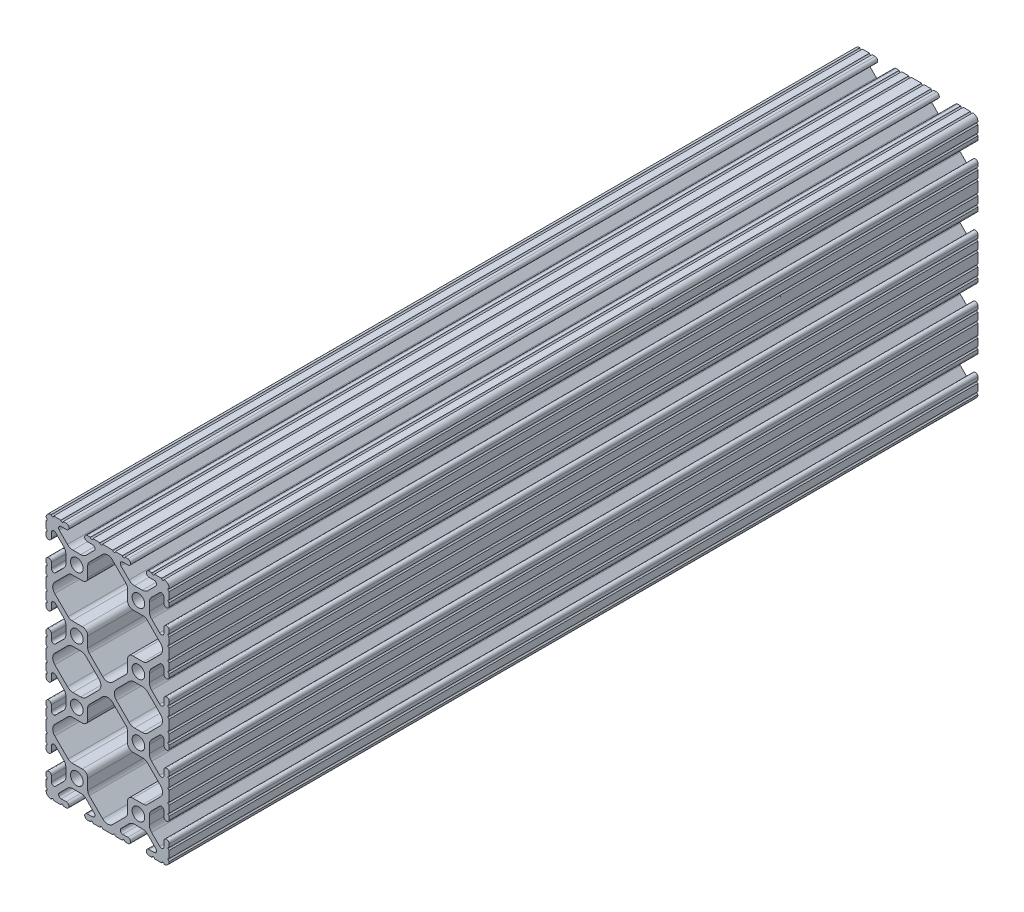
from build123d import *

# Parameters (mm, degrees)
SKETCH1_R      = 2.6035
EXTRUDE1_DEPTH = 333.375


with BuildPart() as part:
    # Sketch1 → Extrude1 (new body)
    with BuildSketch(Plane.XY):
        with BuildLine():
            Line((-12.699984366, 40.2336), (-12.699984366, 35.9664))
            ThreePointArc((-12.699984366, 35.9664), (-12.192, 35.458392183), (-12.7, 34.9504))
            Line((-12.7, 34.9504), (-12.7, 32.004))
            ThreePointArc((-12.7, 32.004), (-12.192, 31.496), (-12.7, 30.988))
            Line((-12.7, 30.988), (-12.7, 29.7434))
            ThreePointArc((-12.7, 29.7434), (-11.5951, 28.6385), (-10.4902, 29.7434))
            Line((-10.4902, 29.7434), (-10.4902, 31.874256981))
            ThreePointArc((-10.4902, 31.874256981), (-9.863010627, 32.812916821), (-8.755786031, 32.592683991))
            Line((-8.755786031, 32.592683991), (-5.425756348, 29.262714761))
            ThreePointArc((-5.425756348, 29.262714761), (-4.737487999, 28.232663563), (-4.4958, 27.017630353))
            Line((-4.4958, 27.017630353), (-4.4958, 23.782369647))
            ThreePointArc((-4.4958, 23.782369647), (-4.737487999, 22.567336437), (-5.425756348, 21.537285239))
            Line((-5.425756348, 21.537285239), (-8.755786031, 18.207316009))
            ThreePointArc((-8.755786031, 18.207316009), (-9.863010627, 17.987083179), (-10.4902, 18.925743019))
            Line((-10.4902, 18.925743019), (-10.4902, 21.0566))
            ThreePointArc((-10.4902, 21.0566), (-11.5951, 22.1615), (-12.7, 21.0566))
            Line((-12.7, 21.0566), (-12.7, 19.812))
            ThreePointArc((-12.7, 19.812), (-12.192, 19.304), (-12.7, 18.796))
            Line((-12.7, 18.796), (-12.7, 15.8496))
            ThreePointArc((-12.7, 15.8496), (-12.192, 15.341607817), (-12.699984366, 14.8336))
            Line((-12.699984366, 14.8336), (-12.699984366, 10.5664))
            ThreePointArc((-12.699984366, 10.5664), (-12.192, 10.0584), (-12.699984366, 9.5504))
            Line((-12.699984366, 9.5504), (-12.699984366, 6.604))
            ThreePointArc((-12.699984366, 6.604), (-12.192, 6.095992183), (-12.7, 5.588))
            Line((-12.7, 5.588), (-12.7, 4.3434))
            ThreePointArc((-12.7, 4.3434), (-11.5951, 3.2385), (-10.4902, 4.3434))
            Line((-10.4902, 4.3434), (-10.4902, 6.474256981))
            ThreePointArc((-10.4902, 6.474256981), (-9.863010627, 7.412916821), (-8.755786031, 7.192683991))
            Line((-8.755786031, 7.192683991), (-5.425756348, 3.862714761))
            ThreePointArc((-5.425756348, 3.862714761), (-4.737487999, 2.832663563), (-4.4958, 1.617630353))
            Line((-4.4958, 1.617630353), (-4.4958, -1.617630353))
            ThreePointArc((-4.4958, -1.617630353), (-4.737487999, -2.832663563), (-5.425756348, -3.862714761))
            Line((-5.425756348, -3.862714761), (-8.755786031, -7.192683991))
            ThreePointArc((-8.755786031, -7.192683991), (-9.863010627, -7.412916821), (-10.4902, -6.474256981))
            Line((-10.4902, -6.474256981), (-10.4902, -4.3434))
            ThreePointArc((-10.4902, -4.3434), (-11.5951, -3.2385), (-12.7, -4.3434))
            Line((-12.7, -4.3434), (-12.7, -5.588))
            ThreePointArc((-12.7, -5.588), (-12.192, -6.096), (-12.7, -6.604))
            Line((-12.7, -6.604), (-12.7, -9.5504))
            ThreePointArc((-12.7, -9.5504), (-12.192000007, -10.058315768), (-12.699831537, -10.566399972))
            ThreePointArc((-12.699831537, -10.566399972), (-12.082506882, -12.082506882), (-10.566399972, -12.699831537))
            ThreePointArc((-10.566399972, -12.699831537), (-10.058315768, -12.192000007), (-9.5504, -12.7))
            Line((-9.5504, -12.7), (-6.604, -12.7))
            ThreePointArc((-6.604, -12.7), (-6.096, -12.192), (-5.588, -12.7))
            Line((-5.588, -12.7), (-4.3434, -12.7))
            ThreePointArc((-4.3434, -12.7), (-3.2385, -11.5951), (-4.3434, -10.4902))
            Line((-4.3434, -10.4902), (-6.474256981, -10.4902))
            ThreePointArc((-6.474256981, -10.4902), (-7.412916821, -9.863010627), (-7.192683991, -8.755786031))
            Line((-7.192683991, -8.755786031), (-3.862714761, -5.425756348))
            ThreePointArc((-3.862714761, -5.425756348), (-2.832663563, -4.737487999), (-1.617630353, -4.4958))
            Line((-1.617630353, -4.4958), (1.617630353, -4.4958))
            ThreePointArc((1.617630353, -4.4958), (2.832663563, -4.737487999), (3.862714761, -5.425756348))
            Line((3.862714761, -5.425756348), (7.192683991, -8.755786031))
            ThreePointArc((7.192683991, -8.755786031), (7.412916821, -9.863010627), (6.474256981, -10.4902))
            Line((6.474256981, -10.4902), (4.3434, -10.4902))
            ThreePointArc((4.3434, -10.4902), (3.2385, -11.5951), (4.3434, -12.7))
            Line((4.3434, -12.7), (5.588, -12.7))
            ThreePointArc((5.588, -12.7), (6.096, -12.192), (6.604, -12.7))
            Line((6.604, -12.7), (9.5504, -12.7))
            ThreePointArc((9.5504, -12.7), (10.0584, -12.192), (10.5664, -12.7))
            Line((10.5664, -12.7), (14.8336, -12.7))
            ThreePointArc((14.8336, -12.7), (15.3416, -12.192), (15.8496, -12.7))
            Line((15.8496, -12.7), (18.796, -12.7))
            ThreePointArc((18.796, -12.7), (19.304, -12.192), (19.812, -12.7))
            Line((19.812, -12.7), (21.0566, -12.7))
            ThreePointArc((21.0566, -12.7), (22.1615, -11.5951), (21.0566, -10.4902))
            Line((21.0566, -10.4902), (18.925743019, -10.4902))
            ThreePointArc((18.925743019, -10.4902), (17.987083179, -9.863010627), (18.207316009, -8.755786031))
            Line((18.207316009, -8.755786031), (21.537285239, -5.425756348))
            ThreePointArc((21.537285239, -5.425756348), (22.567336437, -4.737487999), (23.782369647, -4.4958))
            Line((23.782369647, -4.4958), (27.017630353, -4.4958))
            ThreePointArc((27.017630353, -4.4958), (28.232663563, -4.737487999), (29.262714761, -5.425756348))
            Line((29.262714761, -5.425756348), (32.592683991, -8.755786031))
            ThreePointArc((32.592683991, -8.755786031), (32.812916821, -9.863010627), (31.874256981, -10.4902))
            Line((31.874256981, -10.4902), (29.7434, -10.4902))
            ThreePointArc((29.7434, -10.4902), (28.6385, -11.5951), (29.7434, -12.7))
            Line((29.7434, -12.7), (30.988, -12.7))
            ThreePointArc((30.988, -12.7), (31.496, -12.192), (32.004, -12.7))
            Line((32.004, -12.7), (34.9504, -12.7))
            ThreePointArc((34.9504, -12.7), (35.458315768, -12.192000007), (35.966399972, -12.699831537))
            ThreePointArc((35.966399972, -12.699831537), (37.482506882, -12.082506882), (38.099831537, -10.566399972))
            ThreePointArc((38.099831537, -10.566399972), (37.592000007, -10.058315768), (38.1, -9.5504))
            Line((38.1, -9.5504), (38.1, -6.604))
            ThreePointArc((38.1, -6.604), (37.592, -6.096), (38.1, -5.588))
            Line((38.1, -5.588), (38.1, -4.3434))
            ThreePointArc((38.1, -4.3434), (36.9951, -3.2385), (35.8902, -4.3434))
            Line((35.8902, -4.3434), (35.8902, -6.474256981))
            ThreePointArc((35.8902, -6.474256981), (35.263010627, -7.412916821), (34.155786031, -7.192683991))
            Line((34.155786031, -7.192683991), (30.825756348, -3.862714761))
            ThreePointArc((30.825756348, -3.862714761), (30.137487999, -2.832663563), (29.8958, -1.617630353))
            Line((29.8958, -1.617630353), (29.8958, 1.617630353))
            ThreePointArc((29.8958, 1.617630353), (30.137487999, 2.832663563), (30.825756348, 3.862714761))
            Line((30.825756348, 3.862714761), (34.155786031, 7.192683991))
            ThreePointArc((34.155786031, 7.192683991), (35.263010627, 7.412916821), (35.8902, 6.474256981))
            Line((35.8902, 6.474256981), (35.8902, 4.3434))
            ThreePointArc((35.8902, 4.3434), (36.9951, 3.2385), (38.1, 4.3434))
            Line((38.1, 4.3434), (38.1, 5.588))
            ThreePointArc((38.1, 5.588), (37.592, 6.096), (38.1, 6.604))
            Line((38.1, 6.604), (38.1, 9.5504))
            ThreePointArc((38.1, 9.5504), (37.592, 10.058392183), (38.099984366, 10.5664))
            Line((38.099984366, 10.5664), (38.099984366, 14.8336))
            ThreePointArc((38.099984366, 14.8336), (37.592, 15.3416), (38.099984366, 15.8496))
            Line((38.099984366, 15.8496), (38.099984366, 18.796))
            ThreePointArc((38.099984366, 18.796), (37.592, 19.304007817), (38.1, 19.812))
            Line((38.1, 19.812), (38.1, 21.0566))
            ThreePointArc((38.1, 21.0566), (36.9951, 22.1615), (35.8902, 21.0566))
            Line((35.8902, 21.0566), (35.8902, 18.925743019))
            ThreePointArc((35.8902, 18.925743019), (35.263010627, 17.987083179), (34.155786031, 18.207316009))
            Line((34.155786031, 18.207316009), (30.825756348, 21.537285239))
            ThreePointArc((30.825756348, 21.537285239), (30.137487999, 22.567336437), (29.8958, 23.782369647))
            Line((29.8958, 23.782369647), (29.8958, 27.017630353))
            ThreePointArc((29.8958, 27.017630353), (30.137487999, 28.232663563), (30.825756348, 29.262714761))
            Line((30.825756348, 29.262714761), (34.155786031, 32.592683991))
            ThreePointArc((34.155786031, 32.592683991), (35.263010627, 32.812916821), (35.8902, 31.874256981))
            Line((35.8902, 31.874256981), (35.8902, 29.7434))
            ThreePointArc((35.8902, 29.7434), (36.9951, 28.6385), (38.1, 29.7434))
            Line((38.1, 29.7434), (38.1, 30.988))
            ThreePointArc((38.1, 30.988), (37.592, 31.495992183), (38.099984366, 32.004))
            Line((38.099984366, 32.004), (38.099984366, 34.9504))
            ThreePointArc((38.099984366, 34.9504), (37.592, 35.4584), (38.099984366, 35.9664))
            Line((38.099984366, 35.9664), (38.099984366, 40.2336))
            ThreePointArc((38.099984366, 40.2336), (37.592, 40.7416), (38.099984366, 41.2496))
            Line((38.099984366, 41.2496), (38.099984366, 44.196))
            ThreePointArc((38.099984366, 44.196), (37.592, 44.704007817), (38.1, 45.212))
            Line((38.1, 45.212), (38.1, 46.4566))
            ThreePointArc((38.1, 46.4566), (36.9951, 47.5615), (35.8902, 46.4566))
            Line((35.8902, 46.4566), (35.8902, 44.325743019))
            ThreePointArc((35.8902, 44.325743019), (35.263010627, 43.387083179), (34.155786031, 43.607316009))
            Line((34.155786031, 43.607316009), (30.825756348, 46.937285239))
            ThreePointArc((30.825756348, 46.937285239), (30.137487999, 47.967336437), (29.8958, 49.182369647))
            Line((29.8958, 49.182369647), (29.8958, 52.417630353))
            ThreePointArc((29.8958, 52.417630353), (30.137487999, 53.632663563), (30.825756348, 54.662714761))
            Line((30.825756348, 54.662714761), (34.155786031, 57.992683991))
            ThreePointArc((34.155786031, 57.992683991), (35.263010627, 58.212916821), (35.8902, 57.274256981))
            Line((35.8902, 57.274256981), (35.8902, 55.1434))
            ThreePointArc((35.8902, 55.1434), (36.9951, 54.0385), (38.1, 55.1434))
            Line((38.1, 55.1434), (38.1, 56.388))
            ThreePointArc((38.1, 56.388), (37.592, 56.896), (38.1, 57.404))
            Line((38.1, 57.404), (38.1, 60.3504))
            ThreePointArc((38.1, 60.3504), (37.592, 60.858392183), (38.099984366, 61.3664))
            Line((38.099984366, 61.3664), (38.099984366, 65.6336))
            ThreePointArc((38.099984366, 65.6336), (37.592, 66.141607817), (38.1, 66.6496))
            Line((38.1, 66.6496), (38.1, 69.596))
            ThreePointArc((38.1, 69.596), (37.592, 70.104), (38.1, 70.612))
            Line((38.1, 70.612), (38.1, 71.8566))
            ThreePointArc((38.1, 71.8566), (36.9951, 72.9615), (35.8902, 71.8566))
            Line((35.8902, 71.8566), (35.8902, 69.725743019))
            ThreePointArc((35.8902, 69.725743019), (35.263010627, 68.787083179), (34.155786031, 69.007316009))
            Line((34.155786031, 69.007316009), (30.825756348, 72.337285239))
            ThreePointArc((30.825756348, 72.337285239), (30.137487999, 73.367336437), (29.8958, 74.582369647))
            Line((29.8958, 74.582369647), (29.8958, 77.817630353))
            ThreePointArc((29.8958, 77.817630353), (30.137487999, 79.032663563), (30.825756348, 80.062714761))
            Line((30.825756348, 80.062714761), (34.155786031, 83.392683991))
            ThreePointArc((34.155786031, 83.392683991), (35.263010627, 83.612916821), (35.8902, 82.674256981))
            Line((35.8902, 82.674256981), (35.8902, 80.5434))
            ThreePointArc((35.8902, 80.5434), (36.9951, 79.4385), (38.1, 80.5434))
            Line((38.1, 80.5434), (38.1, 81.788))
            ThreePointArc((38.1, 81.788), (37.592, 82.296), (38.1, 82.804))
            Line((38.1, 82.804), (38.1, 85.7504))
            ThreePointArc((38.1, 85.7504), (37.592000007, 86.258315768), (38.099831537, 86.766399972))
            ThreePointArc((38.099831537, 86.766399972), (37.482506882, 88.282506882), (35.966399972, 88.899831537))
            ThreePointArc((35.966399972, 88.899831537), (35.458315768, 88.392000007), (34.9504, 88.9))
            Line((34.9504, 88.9), (32.004, 88.9))
            ThreePointArc((32.004, 88.9), (31.496, 88.392), (30.988, 88.9))
            Line((30.988, 88.9), (29.7434, 88.9))
            ThreePointArc((29.7434, 88.9), (28.6385, 87.7951), (29.7434, 86.6902))
            Line((29.7434, 86.6902), (31.874256981, 86.6902))
            ThreePointArc((31.874256981, 86.6902), (32.812916821, 86.063010627), (32.592683991, 84.955786031))
            Line((32.592683991, 84.955786031), (29.262714761, 81.625756348))
            ThreePointArc((29.262714761, 81.625756348), (28.232663563, 80.937487999), (27.017630353, 80.6958))
            Line((27.017630353, 80.6958), (23.782369647, 80.6958))
            ThreePointArc((23.782369647, 80.6958), (22.567336437, 80.937487999), (21.537285239, 81.625756348))
            Line((21.537285239, 81.625756348), (18.207316009, 84.955786031))
            ThreePointArc((18.207316009, 84.955786031), (17.987083179, 86.063010627), (18.925743019, 86.6902))
            Line((18.925743019, 86.6902), (21.0566, 86.6902))
            ThreePointArc((21.0566, 86.6902), (22.1615, 87.7951), (21.0566, 88.9))
            Line((21.0566, 88.9), (19.812, 88.9))
            ThreePointArc((19.812, 88.9), (19.304, 88.392), (18.796, 88.9))
            Line((18.796, 88.9), (15.8496, 88.9))
            ThreePointArc((15.8496, 88.9), (15.3416, 88.392), (14.8336, 88.9))
            Line((14.8336, 88.9), (10.5664, 88.9))
            ThreePointArc((10.5664, 88.9), (10.0584, 88.392), (9.5504, 88.9))
            Line((9.5504, 88.9), (6.604, 88.9))
            ThreePointArc((6.604, 88.9), (6.096, 88.392), (5.588, 88.9))
            Line((5.588, 88.9), (4.3434, 88.9))
            ThreePointArc((4.3434, 88.9), (3.2385, 87.7951), (4.3434, 86.6902))
            Line((4.3434, 86.6902), (6.474256981, 86.6902))
            ThreePointArc((6.474256981, 86.6902), (7.412916821, 86.063010627), (7.192683991, 84.955786031))
            Line((7.192683991, 84.955786031), (3.862714761, 81.625756348))
            ThreePointArc((3.862714761, 81.625756348), (2.832663563, 80.937487999), (1.617630353, 80.6958))
            Line((1.617630353, 80.6958), (-1.617630353, 80.6958))
            ThreePointArc((-1.617630353, 80.6958), (-2.832663563, 80.937487999), (-3.862714761, 81.625756348))
            Line((-3.862714761, 81.625756348), (-7.192683991, 84.955786031))
            ThreePointArc((-7.192683991, 84.955786031), (-7.412916821, 86.063010627), (-6.474256981, 86.6902))
            Line((-6.474256981, 86.6902), (-4.3434, 86.6902))
            ThreePointArc((-4.3434, 86.6902), (-3.2385, 87.7951), (-4.3434, 88.9))
            Line((-4.3434, 88.9), (-5.588, 88.9))
            ThreePointArc((-5.588, 88.9), (-6.096, 88.392), (-6.604, 88.9))
            Line((-6.604, 88.9), (-9.5504, 88.9))
            ThreePointArc((-9.5504, 88.9), (-10.058315768, 88.392000007), (-10.566399972, 88.899831537))
            ThreePointArc((-10.566399972, 88.899831537), (-12.082506882, 88.282506882), (-12.699831537, 86.766399972))
            ThreePointArc((-12.699831537, 86.766399972), (-12.192000007, 86.258315768), (-12.7, 85.7504))
            Line((-12.7, 85.7504), (-12.7, 82.804))
            ThreePointArc((-12.7, 82.804), (-12.192, 82.296), (-12.7, 81.788))
            Line((-12.7, 81.788), (-12.7, 80.5434))
            ThreePointArc((-12.7, 80.5434), (-11.5951, 79.4385), (-10.4902, 80.5434))
            Line((-10.4902, 80.5434), (-10.4902, 82.674256981))
            ThreePointArc((-10.4902, 82.674256981), (-9.863010627, 83.612916821), (-8.755786031, 83.392683991))
            Line((-8.755786031, 83.392683991), (-5.425756348, 80.062714761))
            ThreePointArc((-5.425756348, 80.062714761), (-4.737487999, 79.032663563), (-4.4958, 77.817630353))
            Line((-4.4958, 77.817630353), (-4.4958, 74.582369647))
            ThreePointArc((-4.4958, 74.582369647), (-4.737487999, 73.367336437), (-5.425756348, 72.337285239))
            Line((-5.425756348, 72.337285239), (-8.755786031, 69.007316009))
            ThreePointArc((-8.755786031, 69.007316009), (-9.863010627, 68.787083179), (-10.4902, 69.725743019))
            Line((-10.4902, 69.725743019), (-10.4902, 71.8566))
            ThreePointArc((-10.4902, 71.8566), (-11.5951, 72.9615), (-12.7, 71.8566))
            Line((-12.7, 71.8566), (-12.7, 70.612))
            ThreePointArc((-12.7, 70.612), (-12.192, 70.104), (-12.7, 69.596))
            Line((-12.7, 69.596), (-12.7, 66.6496))
            ThreePointArc((-12.7, 66.6496), (-12.192, 66.141607817), (-12.699984366, 65.6336))
            Line((-12.699984366, 65.6336), (-12.699984366, 61.3664))
            ThreePointArc((-12.699984366, 61.3664), (-12.192, 60.858392183), (-12.7, 60.3504))
            Line((-12.7, 60.3504), (-12.7, 57.404))
            ThreePointArc((-12.7, 57.404), (-12.192, 56.896), (-12.7, 56.388))
            Line((-12.7, 56.388), (-12.7, 55.1434))
            ThreePointArc((-12.7, 55.1434), (-11.5951, 54.0385), (-10.4902, 55.1434))
            Line((-10.4902, 55.1434), (-10.4902, 57.274256981))
            ThreePointArc((-10.4902, 57.274256981), (-9.863010627, 58.212916821), (-8.755786031, 57.992683991))
            Line((-8.755786031, 57.992683991), (-5.425756348, 54.662714761))
            ThreePointArc((-5.425756348, 54.662714761), (-4.737487999, 53.632663563), (-4.4958, 52.417630353))
            Line((-4.4958, 52.417630353), (-4.4958, 49.182369647))
            ThreePointArc((-4.4958, 49.182369647), (-4.737487999, 47.967336437), (-5.425756348, 46.937285239))
            Line((-5.425756348, 46.937285239), (-8.755786031, 43.607316009))
            ThreePointArc((-8.755786031, 43.607316009), (-9.863010627, 43.387083179), (-10.4902, 44.325743019))
            Line((-10.4902, 44.325743019), (-10.4902, 46.4566))
            ThreePointArc((-10.4902, 46.4566), (-11.5951, 47.5615), (-12.7, 46.4566))
            Line((-12.7, 46.4566), (-12.7, 45.212))
            ThreePointArc((-12.7, 45.212), (-12.192, 44.704), (-12.7, 44.196))
            Line((-12.7, 44.196), (-12.7, 41.2496))
            ThreePointArc((-12.7, 41.2496), (-12.192, 40.741607817), (-12.699984366, 40.2336))
        make_face()
        with Locations((25.4, 76.2)):
            Circle(SKETCH1_R, mode=Mode.SUBTRACT)
        with Locations((0, 76.2)):
            Circle(SKETCH1_R, mode=Mode.SUBTRACT)
        with Locations((25.4, 50.8)):
            Circle(SKETCH1_R, mode=Mode.SUBTRACT)
        with Locations((0, 50.8)):
            Circle(SKETCH1_R, mode=Mode.SUBTRACT)
        with Locations((25.4, 0)):
            Circle(SKETCH1_R, mode=Mode.SUBTRACT)
        Circle(SKETCH1_R, mode=Mode.SUBTRACT)
        with Locations((25.4, 25.4)):
            Circle(SKETCH1_R, mode=Mode.SUBTRACT)
        with Locations((0, 25.4)):
            Circle(SKETCH1_R, mode=Mode.SUBTRACT)
        with BuildLine():
            Line((2.286, 55.2958), (-2.018378203, 55.2958))
            ThreePointArc((-2.018378203, 55.2958), (-2.864022786, 55.464007171), (-3.580928584, 55.943021252))
            Line((-3.580928584, 55.943021252), (-9.072529371, 61.434522344))
            ThreePointArc((-9.072529371, 61.434522344), (-9.928089211, 63.5), (-9.072529371, 65.565477656))
            Line((-9.072529371, 65.565477656), (-3.580928584, 71.056978748))
            ThreePointArc((-3.580928584, 71.056978748), (-2.864022786, 71.535992829), (-2.018378203, 71.7042))
            Line((-2.018378203, 71.7042), (2.286, 71.7042))
            ThreePointArc((2.286, 71.7042), (3.848564565, 72.351435435), (4.4958, 73.914))
            Line((4.4958, 73.914), (4.4958, 78.218378203))
            ThreePointArc((4.4958, 78.218378203), (4.664007171, 79.064022786), (5.143021252, 79.780928584))
            Line((5.143021252, 79.780928584), (10.634522344, 85.272529371))
            ThreePointArc((10.634522344, 85.272529371), (12.7, 86.128089211), (14.765477656, 85.272529371))
            Line((14.765477656, 85.272529371), (20.256978748, 79.780928584))
            ThreePointArc((20.256978748, 79.780928584), (20.735992829, 79.064022786), (20.9042, 78.218378203))
            Line((20.9042, 78.218378203), (20.9042, 73.914))
            ThreePointArc((20.9042, 73.914), (21.551435435, 72.351435435), (23.114, 71.7042))
            Line((23.114, 71.7042), (27.418378203, 71.7042))
            ThreePointArc((27.418378203, 71.7042), (28.264022786, 71.535992829), (28.980928584, 71.056978748))
            Line((28.980928584, 71.056978748), (34.472529371, 65.565477656))
            ThreePointArc((34.472529371, 65.565477656), (35.328089211, 63.5), (34.472529371, 61.434522344))
            Line((34.472529371, 61.434522344), (28.980928584, 55.943021252))
            ThreePointArc((28.980928584, 55.943021252), (28.264022786, 55.464007171), (27.418378203, 55.2958))
            Line((27.418378203, 55.2958), (23.114, 55.2958))
            ThreePointArc((23.114, 55.2958), (21.551435435, 54.648564565), (20.9042, 53.086))
            Line((20.9042, 53.086), (20.9042, 48.781621797))
            ThreePointArc((20.9042, 48.781621797), (20.735992829, 47.935977214), (20.256978748, 47.219071416))
            Line((20.256978748, 47.219071416), (14.765477656, 41.727470629))
            ThreePointArc((14.765477656, 41.727470629), (12.7, 40.871910789), (10.634522344, 41.727470629))
            Line((10.634522344, 41.727470629), (5.143021252, 47.219071416))
            ThreePointArc((5.143021252, 47.219071416), (4.664007171, 47.935977214), (4.4958, 48.781621797))
            Line((4.4958, 48.781621797), (4.4958, 53.086))
            ThreePointArc((4.4958, 53.086), (3.848564565, 54.648564565), (2.286, 55.2958))
        make_face(mode=Mode.SUBTRACT)
        with BuildLine():
            Line((4.4958, 23.114), (4.4958, 27.418378203))
            ThreePointArc((4.4958, 27.418378203), (4.664007171, 28.264022786), (5.143021252, 28.980928584))
            Line((5.143021252, 28.980928584), (10.634522344, 34.472529371))
            ThreePointArc((10.634522344, 34.472529371), (12.7, 35.328089211), (14.765477656, 34.472529371))
            Line((14.765477656, 34.472529371), (20.256978748, 28.980928584))
            ThreePointArc((20.256978748, 28.980928584), (20.735992829, 28.264022786), (20.9042, 27.418378203))
            Line((20.9042, 27.418378203), (20.9042, 23.114))
            ThreePointArc((20.9042, 23.114), (21.551435435, 21.551435435), (23.114, 20.9042))
            Line((23.114, 20.9042), (27.418378203, 20.9042))
            ThreePointArc((27.418378203, 20.9042), (28.264022786, 20.735992829), (28.980928584, 20.256978748))
            Line((28.980928584, 20.256978748), (34.472529371, 14.765477656))
            ThreePointArc((34.472529371, 14.765477656), (35.328089211, 12.7), (34.472529371, 10.634522344))
            Line((34.472529371, 10.634522344), (28.980928584, 5.143021252))
            ThreePointArc((28.980928584, 5.143021252), (28.264022786, 4.664007171), (27.418378203, 4.4958))
            Line((27.418378203, 4.4958), (23.114, 4.4958))
            ThreePointArc((23.114, 4.4958), (21.551435435, 3.848564565), (20.9042, 2.286))
            Line((20.9042, 2.286), (20.9042, -2.018378203))
            ThreePointArc((20.9042, -2.018378203), (20.735992829, -2.864022786), (20.256978748, -3.580928584))
            Line((20.256978748, -3.580928584), (14.765477656, -9.072529371))
            ThreePointArc((14.765477656, -9.072529371), (12.7, -9.928089211), (10.634522344, -9.072529371))
            Line((10.634522344, -9.072529371), (5.143021252, -3.580928584))
            ThreePointArc((5.143021252, -3.580928584), (4.664007171, -2.864022786), (4.4958, -2.018378203))
            Line((4.4958, -2.018378203), (4.4958, 2.286))
            ThreePointArc((4.4958, 2.286), (3.848564565, 3.848564565), (2.286, 4.4958))
            Line((2.286, 4.4958), (-2.018378203, 4.4958))
            ThreePointArc((-2.018378203, 4.4958), (-2.864022786, 4.664007171), (-3.580928584, 5.143021252))
            Line((-3.580928584, 5.143021252), (-9.072529371, 10.634522344))
            ThreePointArc((-9.072529371, 10.634522344), (-9.928089211, 12.7), (-9.072529371, 14.765477656))
            Line((-9.072529371, 14.765477656), (-3.580928584, 20.256978748))
            ThreePointArc((-3.580928584, 20.256978748), (-2.864022786, 20.735992829), (-2.018378203, 20.9042))
            Line((-2.018378203, 20.9042), (2.286, 20.9042))
            ThreePointArc((2.286, 20.9042), (3.848564565, 21.551435435), (4.4958, 23.114))
        make_face(mode=Mode.SUBTRACT)
        with BuildLine():
            Line((27.018584404, 29.8958), (23.782369647, 29.8958))
            ThreePointArc((23.782369647, 29.8958), (22.567336437, 30.137487999), (21.537285239, 30.825756348))
            Line((21.537285239, 30.825756348), (16.328576307, 36.03455984))
            ThreePointArc((16.328576307, 36.03455984), (15.473053963, 38.1), (16.328576307, 40.16544016))
            Line((16.328576307, 40.16544016), (21.537285239, 45.374243652))
            ThreePointArc((21.537285239, 45.374243652), (22.567336437, 46.062512001), (23.782369647, 46.3042))
            Line((23.782369647, 46.3042), (27.018584404, 46.3042))
            ThreePointArc((27.018584404, 46.3042), (28.233590989, 46.06252303), (29.263628056, 45.374284409))
            Line((29.263628056, 45.374284409), (34.472529371, 40.165477656))
            ThreePointArc((34.472529371, 40.165477656), (35.328089211, 38.1), (34.472529371, 36.034522344))
            Line((34.472529371, 36.034522344), (29.263628056, 30.825715591))
            ThreePointArc((29.263628056, 30.825715591), (28.233590989, 30.13747697), (27.018584404, 29.8958))
        make_face(mode=Mode.SUBTRACT)
        with BuildLine():
            Line((1.617630353, 29.8958), (-1.618584404, 29.8958))
            ThreePointArc((-1.618584404, 29.8958), (-2.833590989, 30.13747697), (-3.863628056, 30.825715591))
            Line((-3.863628056, 30.825715591), (-9.072529371, 36.034522344))
            ThreePointArc((-9.072529371, 36.034522344), (-9.928089211, 38.1), (-9.072529371, 40.165477656))
            Line((-9.072529371, 40.165477656), (-3.863628056, 45.374284409))
            ThreePointArc((-3.863628056, 45.374284409), (-2.833590989, 46.06252303), (-1.618584404, 46.3042))
            Line((-1.618584404, 46.3042), (1.617630353, 46.3042))
            ThreePointArc((1.617630353, 46.3042), (2.832663563, 46.062512001), (3.862714761, 45.374243652))
            Line((3.862714761, 45.374243652), (9.071423693, 40.16544016))
            ThreePointArc((9.071423693, 40.16544016), (9.926946037, 38.1), (9.071423693, 36.03455984))
            Line((9.071423693, 36.03455984), (3.862714761, 30.825756348))
            ThreePointArc((3.862714761, 30.825756348), (2.832663563, 30.137487999), (1.617630353, 29.8958))
        make_face(mode=Mode.SUBTRACT)
    extrude(amount=-EXTRUDE1_DEPTH)


solid = part.part
